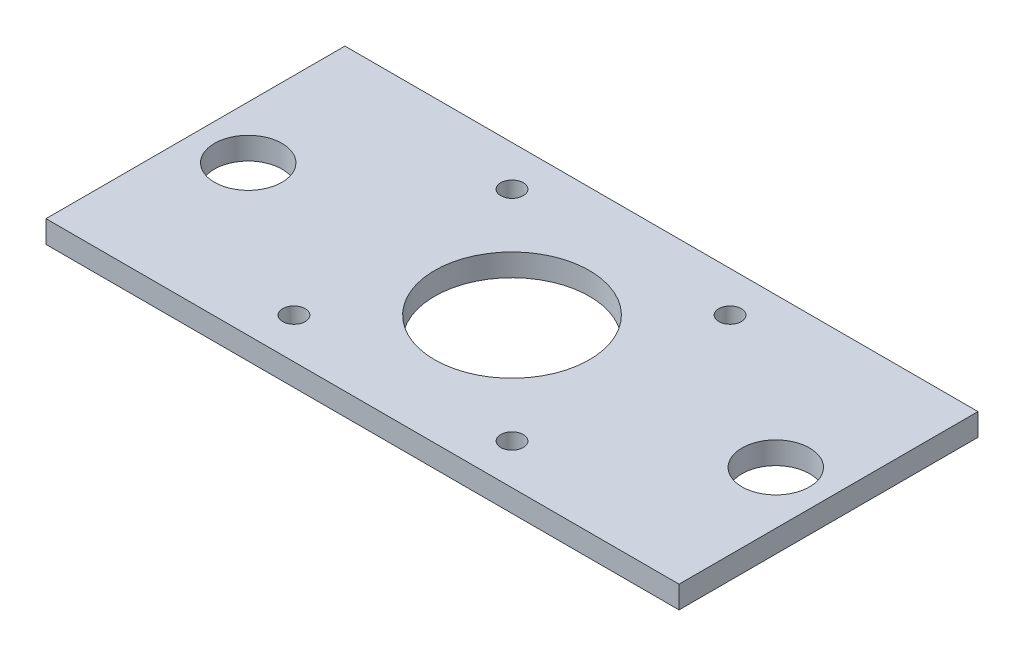
from build123d import *

# Parameters (mm, degrees)
SKETCH2_W           = 90
SKETCH2_H           = 42.5
SKETCH2_R           = 11
SKETCH2_R_2         = 1.6
SKETCH2_R_3         = 4.79806
BOSS_EXTRUDE1_DEPTH = 3.175


with BuildPart() as part:
    # Sketch2 → Boss-Extrude1 (new body)
    with BuildSketch(Plane(origin=(0, 0, 0), x_dir=(1, 0, 0), z_dir=(0, 1, 0))):
        Rectangle(SKETCH2_W, SKETCH2_H)
        Circle(SKETCH2_R, mode=Mode.SUBTRACT)
        with Locations((-15.5, 15.5)):
            Circle(SKETCH2_R_2, mode=Mode.SUBTRACT)
        with Locations((15.5, 15.5)):
            Circle(SKETCH2_R_2, mode=Mode.SUBTRACT)
        with Locations((15.5, -15.5)):
            Circle(SKETCH2_R_2, mode=Mode.SUBTRACT)
        with Locations((-15.5, -15.5)):
            Circle(SKETCH2_R_2, mode=Mode.SUBTRACT)
        with Locations((-37.5, 0)):
            Circle(SKETCH2_R_3, mode=Mode.SUBTRACT)
        with Locations((37.5, 0)):
            Circle(SKETCH2_R_3, mode=Mode.SUBTRACT)
    extrude(amount=BOSS_EXTRUDE1_DEPTH)


solid = part.part
